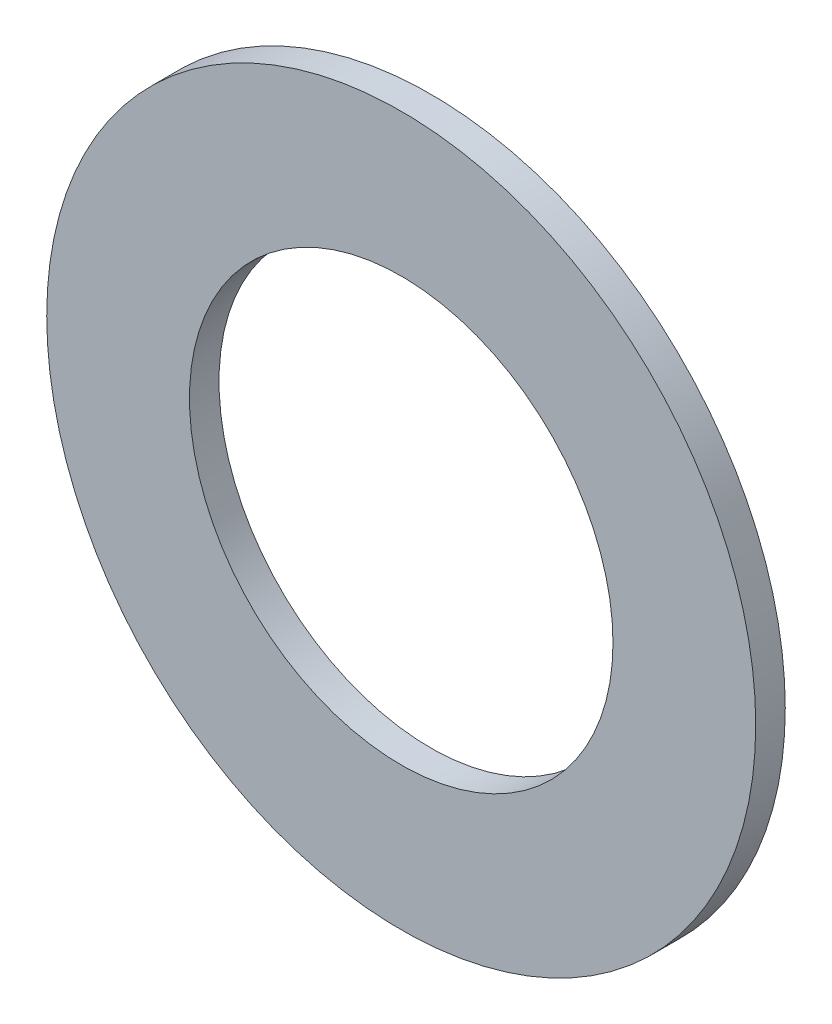
from build123d import *

# Parameters (mm, degrees)
SKETCH1_R      = 19.05
SKETCH1_R_2    = 11.3792
EXTRUDE1_DEPTH = 0.79375


with BuildPart() as part:
    # Sketch1 → Extrude1 (new body, symmetric)
    with BuildSketch(Plane.XY):
        Circle(SKETCH1_R)
        Circle(SKETCH1_R_2, mode=Mode.SUBTRACT)
    extrude(amount=EXTRUDE1_DEPTH, both=True)


solid = part.part
